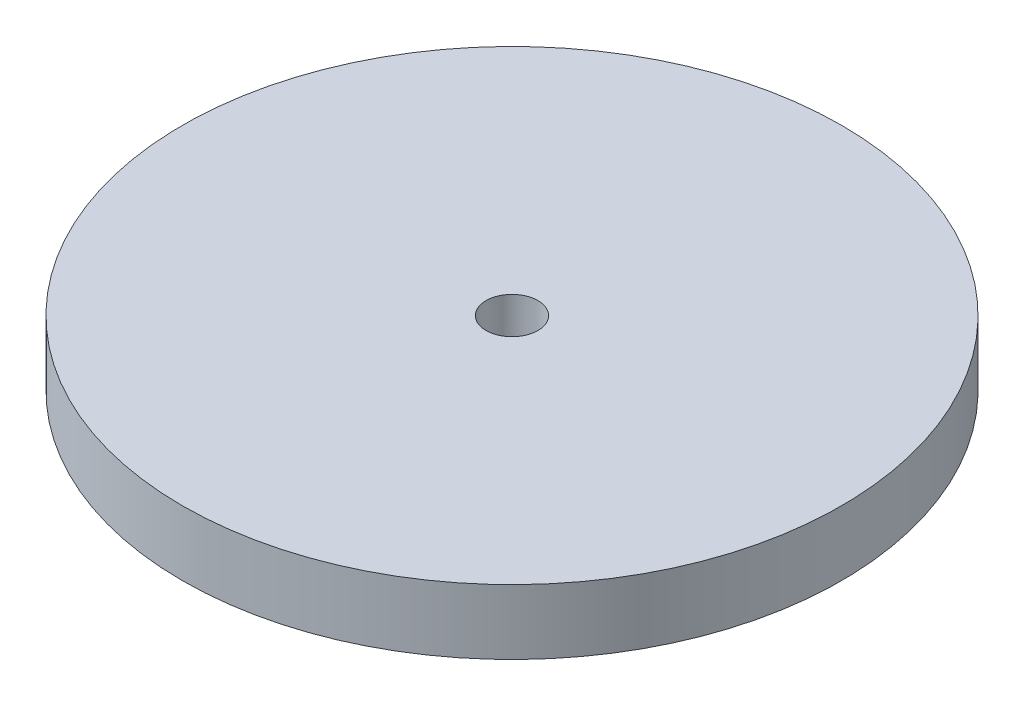
from build123d import *

# Parameters (mm, degrees)
SKETCH1_R           = 50.8
BOSS_EXTRUDE1_DEPTH = 10
SKETCH2_R           = 4
CUT_EXTRUDE1_DEPTH  = 11


with BuildPart() as part:
    # Sketch1 → Boss-Extrude1 (new body)
    with BuildSketch(Plane(origin=(0, 0, 0), x_dir=(1, 0, 0), z_dir=(0, 1, 0))):
        Circle(SKETCH1_R)
    extrude(amount=BOSS_EXTRUDE1_DEPTH)

    # Sketch2 → Cut-Extrude1 (cut, through all)
    with BuildSketch(Plane(origin=(0, 10, 0), x_dir=(1, 0, 0), z_dir=(0, 1, 0))):
        Circle(SKETCH2_R)
    extrude(amount=-CUT_EXTRUDE1_DEPTH, mode=Mode.SUBTRACT)


solid = part.part
